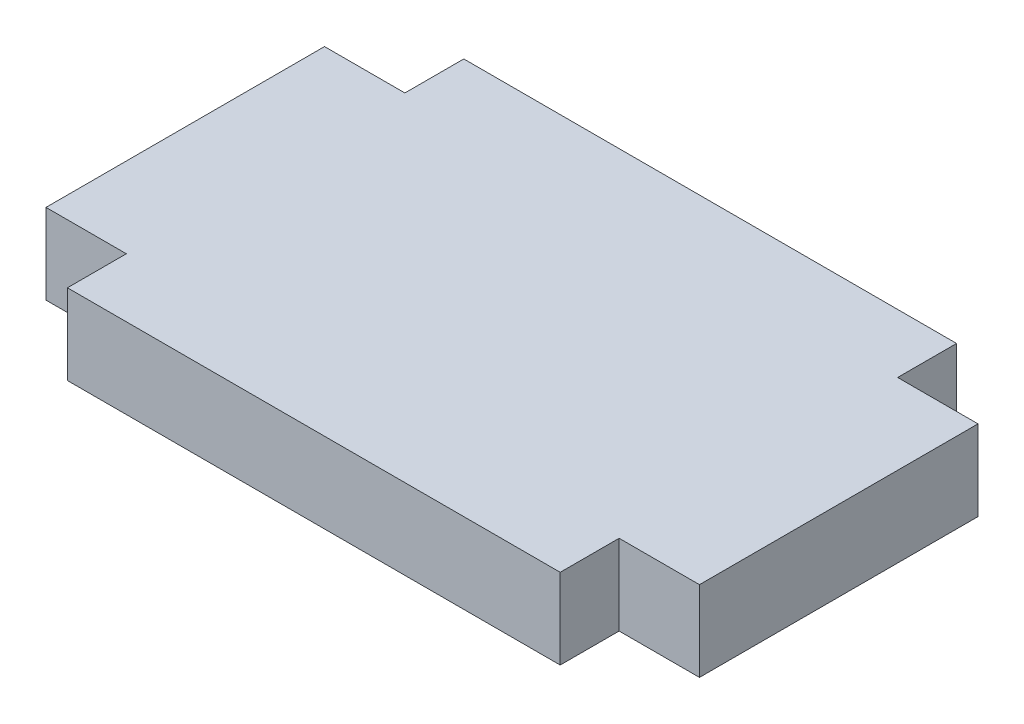
from build123d import *

# Parameters (mm, degrees)
BOSS_EXTRUDE1_DEPTH = 9.525


with BuildPart() as part:
    # Sketch1 → Boss-Extrude1 (new body)
    with BuildSketch(Plane(origin=(0, 0, 0), x_dir=(1, 0, 0), z_dir=(0, 1, 0))):
        Polygon((9.525, -46.99), (67.945, -46.99), (67.945, -40.005), (77.47, -40.005), (77.47, -6.985), (67.945, -6.985), (67.945, 0), (9.525, 0), (9.525, -6.985), (0, -6.985), (0, -40.005), (9.525, -40.005), align=None)
    extrude(amount=BOSS_EXTRUDE1_DEPTH)


solid = part.part
